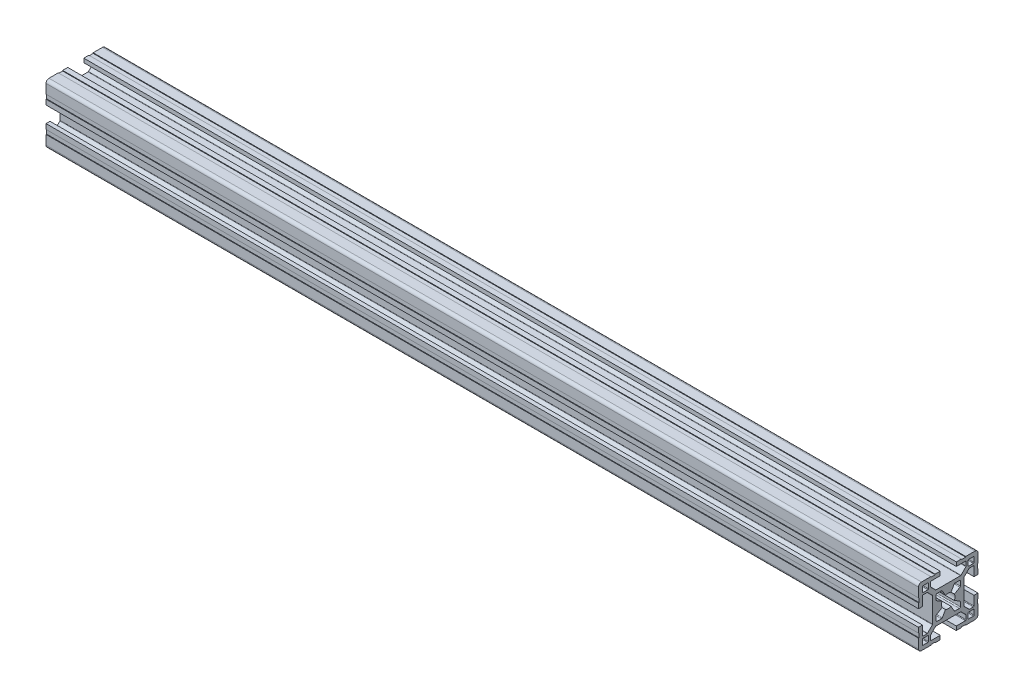
from build123d import *

# Parameters (mm, degrees)
QUADRADO_PF30_11_PERFIL_3030_CENTRO_M8_DEPTH = 440


with BuildPart() as part:
    # Sketch1 → Quadrado PF30-11 - PERFIL 3030 CENTRO M8(1) (new body)
    with BuildSketch(Plane.YZ):
        with BuildLine():
            Line((14.999995923, 6.599996803), (14.699995923, 6.599996803))
            Line((14.699995923, 6.599996803), (14.699995923, 8.799996803))
            Line((14.699995923, 8.799996803), (14.999995923, 8.799996803))
            Line((14.999995923, 8.799996803), (14.999995923, 13.499995825))
            ThreePointArc((14.999995923, 13.499995825), (14.560656066, 14.560656066), (13.499995825, 14.999995923))
            Line((13.499995825, 14.999995923), (8.799996818, 14.999995923))
            Line((8.799996818, 14.999995923), (8.799996818, 14.699995923))
            Line((8.799996818, 14.699995923), (6.599996818, 14.699995923))
            Line((6.599996818, 14.699995923), (6.599996818, 14.999995923))
            Line((6.599996818, 14.999995923), (4.0499987, 14.999995923))
            Line((4.0499987, 14.999995923), (4.0499987, 12.999995366))
            Line((4.0499987, 12.999995366), (8.699997649, 12.999995366))
            ThreePointArc((8.699997649, 12.999995366), (8.912129683, 12.9121274), (8.999997649, 12.699995366))
            Line((8.999997649, 12.699995366), (8.999997649, 10.679894006))
            ThreePointArc((8.999997649, 10.679894006), (8.977161511, 10.565088981), (8.912129691, 10.467761979))
            Line((8.912129691, 10.467761979), (6.432230191, 7.987862303))
            ThreePointArc((6.432230191, 7.987862303), (6.334903184, 7.922830472), (6.220098149, 7.89999433))
            Line((6.220098149, 7.89999433), (-6.220098149, 7.89999433))
            ThreePointArc((-6.220098149, 7.89999433), (-6.334903184, 7.922830472), (-6.432230191, 7.987862303))
            Line((-6.432230191, 7.987862303), (-8.912129691, 10.467761979))
            ThreePointArc((-8.912129691, 10.467761979), (-8.977161511, 10.565088981), (-8.999997649, 10.679894006))
            Line((-8.999997649, 10.679894006), (-8.999997649, 12.699995366))
            ThreePointArc((-8.999997649, 12.699995366), (-8.912129683, 12.9121274), (-8.699997649, 12.999995366))
            Line((-8.699997649, 12.999995366), (-4.0499987, 12.999995366))
            Line((-4.0499987, 12.999995366), (-4.0499987, 14.999995923))
            Line((-4.0499987, 14.999995923), (-6.599996818, 14.999995923))
            Line((-6.599996818, 14.999995923), (-6.599996818, 14.699995923))
            Line((-6.599996818, 14.699995923), (-8.799996818, 14.699995923))
            Line((-8.799996818, 14.699995923), (-8.799996818, 14.999995923))
            Line((-8.799996818, 14.999995923), (-13.499995825, 14.999995923))
            ThreePointArc((-13.499995825, 14.999995923), (-14.560656066, 14.560656066), (-14.999995923, 13.499995825))
            Line((-14.999995923, 13.499995825), (-14.999995923, 8.799996803))
            Line((-14.999995923, 8.799996803), (-14.699995923, 8.799996803))
            Line((-14.699995923, 8.799996803), (-14.699995923, 6.599996803))
            Line((-14.699995923, 6.599996803), (-14.999995923, 6.599996803))
            Line((-14.999995923, 6.599996803), (-14.999995923, 4.0499987))
            Line((-14.999995923, 4.0499987), (-12.999995366, 4.0499987))
            Line((-12.999995366, 4.0499987), (-12.999995366, 8.699997649))
            ThreePointArc((-12.999995366, 8.699997649), (-12.9121274, 8.912129683), (-12.699995366, 8.999997649))
            Line((-12.699995366, 8.999997649), (-10.679894006, 8.999997649))
            ThreePointArc((-10.679894006, 8.999997649), (-10.565088981, 8.977161511), (-10.467761979, 8.912129691))
            Line((-10.467761979, 8.912129691), (-7.987862303, 6.432230191))
            ThreePointArc((-7.987862303, 6.432230191), (-7.922830472, 6.334903184), (-7.89999433, 6.220098149))
            Line((-7.89999433, 6.220098149), (-7.89999433, -6.220098149))
            ThreePointArc((-7.89999433, -6.220098149), (-7.922830472, -6.334903184), (-7.987862303, -6.432230191))
            Line((-7.987862303, -6.432230191), (-10.467761979, -8.912129691))
            ThreePointArc((-10.467761979, -8.912129691), (-10.565088981, -8.977161511), (-10.679894006, -8.999997649))
            Line((-10.679894006, -8.999997649), (-12.699995366, -8.999997649))
            ThreePointArc((-12.699995366, -8.999997649), (-12.9121274, -8.912129683), (-12.999995366, -8.699997649))
            Line((-12.999995366, -8.699997649), (-12.999995366, -4.0499987))
            Line((-12.999995366, -4.0499987), (-14.999995923, -4.0499987))
            Line((-14.999995923, -4.0499987), (-14.999995923, -6.599996803))
            Line((-14.999995923, -6.599996803), (-14.699995923, -6.599996803))
            Line((-14.699995923, -6.599996803), (-14.699995923, -8.799996803))
            Line((-14.699995923, -8.799996803), (-14.999995923, -8.799996803))
            Line((-14.999995923, -8.799996803), (-14.999995923, -13.499995825))
            ThreePointArc((-14.999995923, -13.499995825), (-14.560656066, -14.560656066), (-13.499995825, -14.999995923))
            Line((-13.499995825, -14.999995923), (-8.799996818, -14.999995923))
            Line((-8.799996818, -14.999995923), (-8.799996818, -14.699995923))
            Line((-8.799996818, -14.699995923), (-6.599996818, -14.699995923))
            Line((-6.599996818, -14.699995923), (-6.599996818, -14.999995923))
            Line((-6.599996818, -14.999995923), (-4.0499987, -14.999995923))
            Line((-4.0499987, -14.999995923), (-4.0499987, -12.999995366))
            Line((-4.0499987, -12.999995366), (-8.699997649, -12.999995366))
            ThreePointArc((-8.699997649, -12.999995366), (-8.912129683, -12.9121274), (-8.999997649, -12.699995366))
            Line((-8.999997649, -12.699995366), (-8.999997649, -10.679894006))
            ThreePointArc((-8.999997649, -10.679894006), (-8.977161511, -10.565088981), (-8.912129691, -10.467761979))
            Line((-8.912129691, -10.467761979), (-6.432230191, -7.987862303))
            ThreePointArc((-6.432230191, -7.987862303), (-6.334903184, -7.922830472), (-6.220098149, -7.89999433))
            Line((-6.220098149, -7.89999433), (6.220098149, -7.89999433))
            ThreePointArc((6.220098149, -7.89999433), (6.334903184, -7.922830472), (6.432230191, -7.987862303))
            Line((6.432230191, -7.987862303), (8.912129691, -10.467761979))
            ThreePointArc((8.912129691, -10.467761979), (8.977161511, -10.565088981), (8.999997649, -10.679894006))
            Line((8.999997649, -10.679894006), (8.999997649, -12.699995366))
            ThreePointArc((8.999997649, -12.699995366), (8.912129683, -12.9121274), (8.699997649, -12.999995366))
            Line((8.699997649, -12.999995366), (4.0499987, -12.999995366))
            Line((4.0499987, -12.999995366), (4.0499987, -14.999995923))
            Line((4.0499987, -14.999995923), (6.599996818, -14.999995923))
            Line((6.599996818, -14.999995923), (6.599996818, -14.699995923))
            Line((6.599996818, -14.699995923), (8.799996818, -14.699995923))
            Line((8.799996818, -14.699995923), (8.799996818, -14.999995923))
            Line((8.799996818, -14.999995923), (13.499995825, -14.999995923))
            ThreePointArc((13.499995825, -14.999995923), (14.560656066, -14.560656066), (14.999995923, -13.499995825))
            Line((14.999995923, -13.499995825), (14.999995923, -8.799996803))
            Line((14.999995923, -8.799996803), (14.699995923, -8.799996803))
            Line((14.699995923, -8.799996803), (14.699995923, -6.599996803))
            Line((14.699995923, -6.599996803), (14.999995923, -6.599996803))
            Line((14.999995923, -6.599996803), (14.999995923, -4.0499987))
            Line((14.999995923, -4.0499987), (12.999995366, -4.0499987))
            Line((12.999995366, -4.0499987), (12.999995366, -8.699997649))
            ThreePointArc((12.999995366, -8.699997649), (12.9121274, -8.912129683), (12.699995366, -8.999997649))
            Line((12.699995366, -8.999997649), (10.679894006, -8.999997649))
            ThreePointArc((10.679894006, -8.999997649), (10.565088981, -8.977161511), (10.467761979, -8.912129691))
            Line((10.467761979, -8.912129691), (7.987862303, -6.432230191))
            ThreePointArc((7.987862303, -6.432230191), (7.922830472, -6.334903184), (7.89999433, -6.220098149))
            Line((7.89999433, -6.220098149), (7.89999433, 6.220098149))
            ThreePointArc((7.89999433, 6.220098149), (7.922830472, 6.334903184), (7.987862303, 6.432230191))
            Line((7.987862303, 6.432230191), (10.467761979, 8.912129691))
            ThreePointArc((10.467761979, 8.912129691), (10.565088981, 8.977161511), (10.679894006, 8.999997649))
            Line((10.679894006, 8.999997649), (12.699995366, 8.999997649))
            ThreePointArc((12.699995366, 8.999997649), (12.9121274, 8.912129683), (12.999995366, 8.699997649))
            Line((12.999995366, 8.699997649), (12.999995366, 4.0499987))
            Line((12.999995366, 4.0499987), (14.999995923, 4.0499987))
            Line((14.999995923, 4.0499987), (14.999995923, 6.599996803))
        make_face()
        with BuildLine():
            Line((-6.1, -3.425408784), (-6.1, -5.6))
            ThreePointArc((-6.1, -5.6), (-5.953553391, -5.953553391), (-5.6, -6.1))
            Line((-5.6, -6.1), (-3.425408784, -6.1))
            ThreePointArc((-3.425408784, -6.1), (-3.175408784, -6.033012702), (-2.992396082, -5.85))
            Line((-2.992396082, -5.85), (-1.402974441, -3.097040962))
            ThreePointArc((-1.402974441, -3.097040962), (0, -3.4), (1.402974441, -3.097040962))
            Line((1.402974441, -3.097040962), (2.992396082, -5.85))
            ThreePointArc((2.992396082, -5.85), (3.175408784, -6.033012702), (3.425408784, -6.1))
            Line((3.425408784, -6.1), (5.6, -6.1))
            ThreePointArc((5.6, -6.1), (5.953553391, -5.953553391), (6.1, -5.6))
            Line((6.1, -5.6), (6.1, -3.425408784))
            ThreePointArc((6.1, -3.425408784), (6.033012702, -3.175408784), (5.85, -2.992396082))
            Line((5.85, -2.992396082), (3.097040962, -1.402974441))
            ThreePointArc((3.097040962, -1.402974441), (3.4, 0), (3.097040962, 1.402974441))
            Line((3.097040962, 1.402974441), (5.85, 2.992396082))
            ThreePointArc((5.85, 2.992396082), (6.033012702, 3.175408784), (6.1, 3.425408784))
            Line((6.1, 3.425408784), (6.1, 5.6))
            ThreePointArc((6.1, 5.6), (5.953553391, 5.953553391), (5.6, 6.1))
            Line((5.6, 6.1), (3.425408784, 6.1))
            ThreePointArc((3.425408784, 6.1), (3.175408784, 6.033012702), (2.992396082, 5.85))
            Line((2.992396082, 5.85), (1.402974441, 3.097040962))
            ThreePointArc((1.402974441, 3.097040962), (0, 3.4), (-1.402974441, 3.097040962))
            Line((-1.402974441, 3.097040962), (-2.992396082, 5.85))
            ThreePointArc((-2.992396082, 5.85), (-3.175408784, 6.033012702), (-3.425408784, 6.1))
            Line((-3.425408784, 6.1), (-5.6, 6.1))
            ThreePointArc((-5.6, 6.1), (-5.953553391, 5.953553391), (-6.1, 5.6))
            Line((-6.1, 5.6), (-6.1, 3.425408784))
            ThreePointArc((-6.1, 3.425408784), (-6.033012702, 3.175408784), (-5.85, 2.992396082))
            Line((-5.85, 2.992396082), (-3.097040962, 1.402974441))
            ThreePointArc((-3.097040962, 1.402974441), (-3.4, 0), (-3.097040962, -1.402974441))
            Line((-3.097040962, -1.402974441), (-5.85, -2.992396082))
            ThreePointArc((-5.85, -2.992396082), (-6.033012702, -3.175408784), (-6.1, -3.425408784))
        make_face(mode=Mode.SUBTRACT)
        with BuildLine():
            Line((9.999995366, 12.699997649), (9.999995366, 10.299997649))
            ThreePointArc((9.999995366, 10.299997649), (10.087863331, 10.087865615), (10.299995366, 9.999997649))
            Line((10.299995366, 9.999997649), (12.699995366, 9.999997649))
            ThreePointArc((12.699995366, 9.999997649), (12.9121274, 10.087865615), (12.999995366, 10.299997649))
            Line((12.999995366, 10.299997649), (12.999995366, 12.699997649))
            ThreePointArc((12.999995366, 12.699997649), (12.9121274, 12.912129683), (12.699995366, 12.999997649))
            Line((12.699995366, 12.999997649), (10.299995366, 12.999997649))
            ThreePointArc((10.299995366, 12.999997649), (10.087863331, 12.912129683), (9.999995366, 12.699997649))
        make_face(mode=Mode.SUBTRACT)
        with BuildLine():
            Line((12.999995366, -12.699997649), (12.999995366, -10.299997649))
            ThreePointArc((12.999995366, -10.299997649), (12.9121274, -10.087865615), (12.699995366, -9.999997649))
            Line((12.699995366, -9.999997649), (10.299995366, -9.999997649))
            ThreePointArc((10.299995366, -9.999997649), (10.087863331, -10.087865615), (9.999995366, -10.299997649))
            Line((9.999995366, -10.299997649), (9.999995366, -12.699997649))
            ThreePointArc((9.999995366, -12.699997649), (10.087863331, -12.912129683), (10.299995366, -12.999997649))
            Line((10.299995366, -12.999997649), (12.699995366, -12.999997649))
            ThreePointArc((12.699995366, -12.999997649), (12.9121274, -12.912129683), (12.999995366, -12.699997649))
        make_face(mode=Mode.SUBTRACT)
        with BuildLine():
            Line((-10.299995366, -9.999997649), (-12.699995366, -9.999997649))
            ThreePointArc((-12.699995366, -9.999997649), (-12.9121274, -10.087865615), (-12.999995366, -10.299997649))
            Line((-12.999995366, -10.299997649), (-12.999995366, -12.699997649))
            ThreePointArc((-12.999995366, -12.699997649), (-12.9121274, -12.912129683), (-12.699995366, -12.999997649))
            Line((-12.699995366, -12.999997649), (-10.299995366, -12.999997649))
            ThreePointArc((-10.299995366, -12.999997649), (-10.087863331, -12.912129683), (-9.999995366, -12.699997649))
            Line((-9.999995366, -12.699997649), (-9.999995366, -10.299997649))
            ThreePointArc((-9.999995366, -10.299997649), (-10.087863331, -10.087865615), (-10.299995366, -9.999997649))
        make_face(mode=Mode.SUBTRACT)
        with BuildLine():
            Line((-12.999995366, 12.699997649), (-12.999995366, 10.299997649))
            ThreePointArc((-12.999995366, 10.299997649), (-12.9121274, 10.087865615), (-12.699995366, 9.999997649))
            Line((-12.699995366, 9.999997649), (-10.299995366, 9.999997649))
            ThreePointArc((-10.299995366, 9.999997649), (-10.087863331, 10.087865615), (-9.999995366, 10.299997649))
            Line((-9.999995366, 10.299997649), (-9.999995366, 12.699997649))
            ThreePointArc((-9.999995366, 12.699997649), (-10.087863331, 12.912129683), (-10.299995366, 12.999997649))
            Line((-10.299995366, 12.999997649), (-12.699995366, 12.999997649))
            ThreePointArc((-12.699995366, 12.999997649), (-12.9121274, 12.912129683), (-12.999995366, 12.699997649))
        make_face(mode=Mode.SUBTRACT)
    extrude(amount=QUADRADO_PF30_11_PERFIL_3030_CENTRO_M8_DEPTH)


solid = part.part
